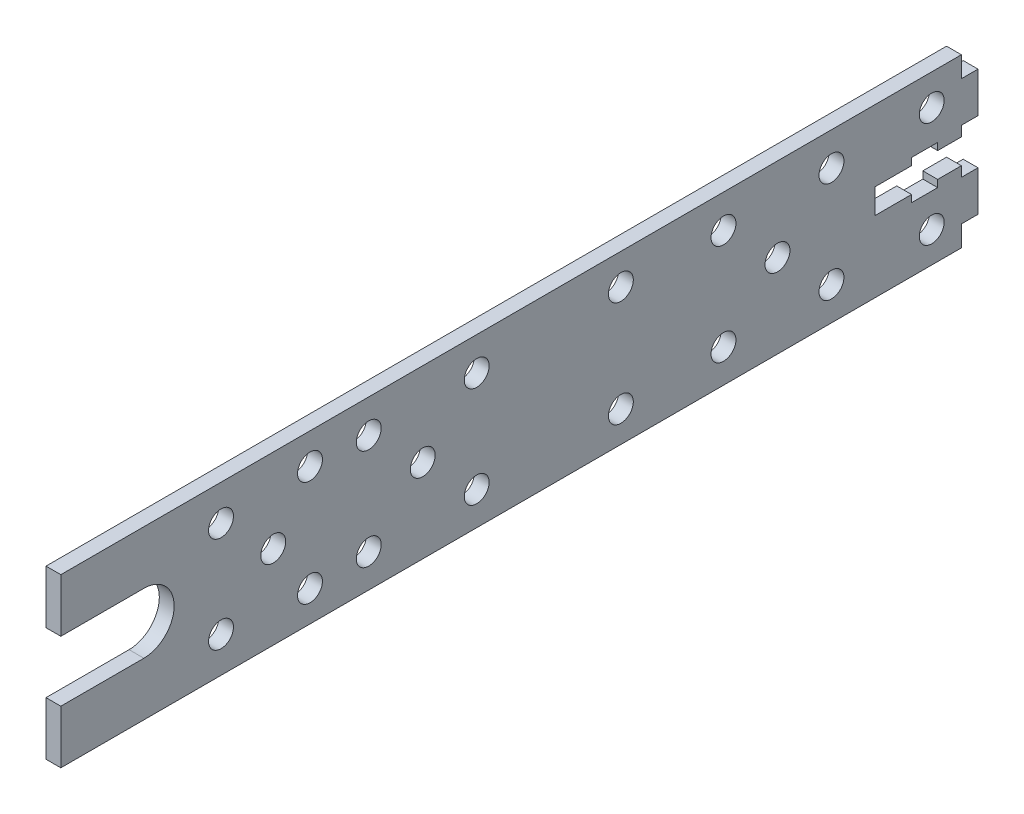
from build123d import *

# Parameters (mm, degrees)
SKETCH1_R           = 2.667
BOSS_EXTRUDE1_DEPTH = 1.5875


with BuildPart() as part:
    # Sketch1 → Boss-Extrude1 (new body, symmetric)
    with BuildSketch(Plane(origin=(0, 0, 0), x_dir=(0, 0, -1), z_dir=(1, 0, 0))):
        with BuildLine():
            Line((-98.171, 17.907), (94.615, 17.907))
            Line((94.615, 17.907), (94.615, 13.462))
            Line((94.615, 13.462), (98.171, 13.462))
            Line((98.171, 13.462), (98.171, 4.826))
            Line((98.171, 4.826), (94.615, 4.826))
            Line((94.615, 4.826), (94.615, 2.667))
            Line((94.615, 2.667), (89.535, 2.667))
            Line((89.535, 2.667), (89.535, 4.191))
            Line((89.535, 4.191), (83.947, 4.191))
            Line((83.947, 4.191), (83.947, 2.667))
            Line((83.947, 2.667), (76.073, 2.667))
            Line((76.073, 2.667), (76.073, -2.667))
            Line((76.073, -2.667), (83.947, -2.667))
            Line((83.947, -2.667), (83.947, -4.191))
            Line((83.947, -4.191), (89.535, -4.191))
            Line((89.535, -4.191), (89.535, -2.667))
            Line((89.535, -2.667), (94.615, -2.667))
            Line((94.615, -2.667), (94.615, -4.826))
            Line((94.615, -4.826), (98.171, -4.826))
            Line((98.171, -4.826), (98.171, -13.462))
            Line((98.171, -13.462), (94.615, -13.462))
            Line((94.615, -13.462), (94.615, -17.907))
            Line((94.615, -17.907), (-98.171, -17.907))
            Line((-98.171, -17.907), (-98.171, -6.477))
            Line((-98.171, -6.477), (-80.391, -6.477))
            ThreePointArc((-80.391, -6.477), (-73.914, 0), (-80.391, 6.477))
            Line((-80.391, 6.477), (-98.171, 6.477))
            Line((-98.171, 6.477), (-98.171, 17.907))
        make_face()
        with Locations((-63.881, 10.287)):
            Circle(SKETCH1_R, mode=Mode.SUBTRACT)
        with Locations((-63.881, -10.287)):
            Circle(SKETCH1_R, mode=Mode.SUBTRACT)
        with Locations((-52.705, 0)):
            Circle(SKETCH1_R, mode=Mode.SUBTRACT)
        with Locations((-44.831, 11.303)):
            Circle(SKETCH1_R, mode=Mode.SUBTRACT)
        with Locations((21.717, 11.303)):
            Circle(SKETCH1_R, mode=Mode.SUBTRACT)
        with Locations((88.265, 11.303)):
            Circle(SKETCH1_R, mode=Mode.SUBTRACT)
        with Locations((88.265, -11.303)):
            Circle(SKETCH1_R, mode=Mode.SUBTRACT)
        with Locations((21.717, -11.303)):
            Circle(SKETCH1_R, mode=Mode.SUBTRACT)
        with Locations((-44.831, -11.303)):
            Circle(SKETCH1_R, mode=Mode.SUBTRACT)
        with Locations((-9.144, 10.795)):
            Circle(SKETCH1_R, mode=Mode.SUBTRACT)
        with Locations((-32.258, 10.795)):
            Circle(SKETCH1_R, mode=Mode.SUBTRACT)
        with Locations((66.802, 10.795)):
            Circle(SKETCH1_R, mode=Mode.SUBTRACT)
        with Locations((43.688, 10.795)):
            Circle(SKETCH1_R, mode=Mode.SUBTRACT)
        with Locations((43.688, -10.795)):
            Circle(SKETCH1_R, mode=Mode.SUBTRACT)
        with Locations((66.802, -10.795)):
            Circle(SKETCH1_R, mode=Mode.SUBTRACT)
        with Locations((-32.258, -10.795)):
            Circle(SKETCH1_R, mode=Mode.SUBTRACT)
        with Locations((-9.144, -10.795)):
            Circle(SKETCH1_R, mode=Mode.SUBTRACT)
        with Locations((-20.701, 0)):
            Circle(SKETCH1_R, mode=Mode.SUBTRACT)
        with Locations((55.245, 0)):
            Circle(SKETCH1_R, mode=Mode.SUBTRACT)
    extrude(amount=BOSS_EXTRUDE1_DEPTH, both=True)


solid = part.part
